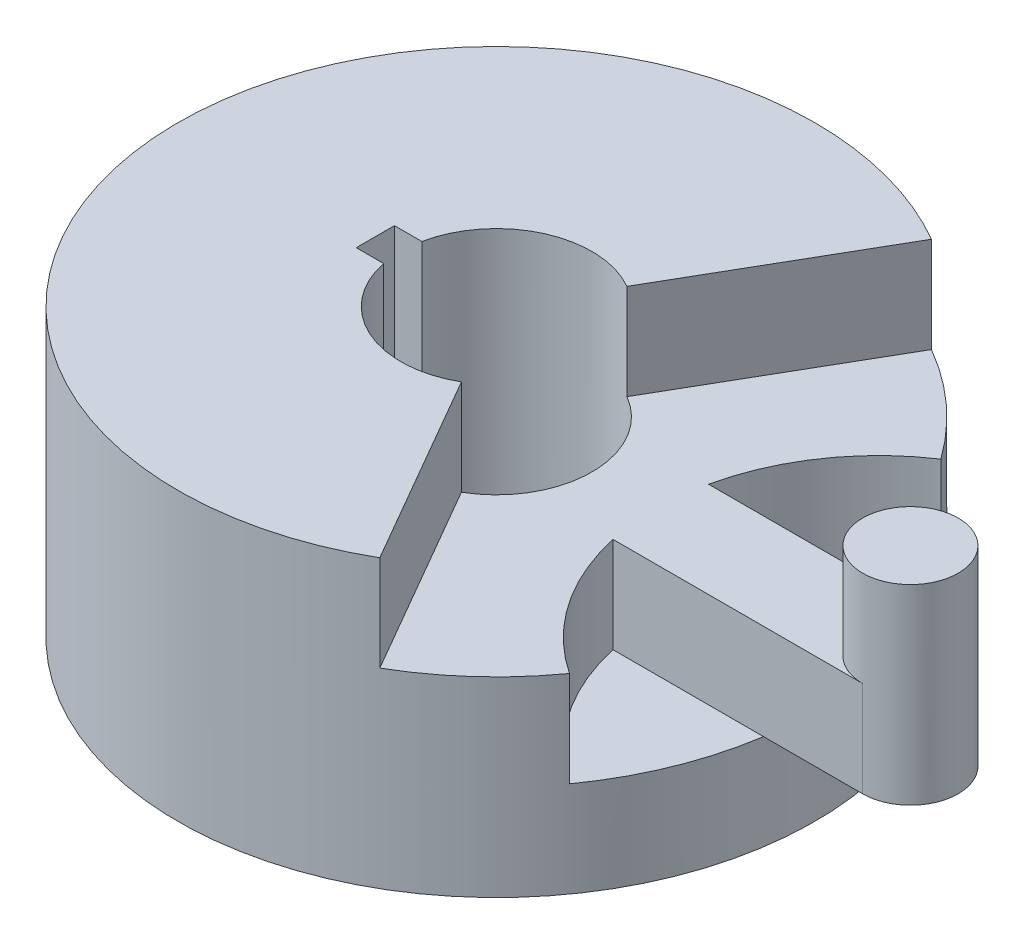
from build123d import *

# Parameters (mm, degrees)
SKETCH1_R           = 15
BOSS_EXTRUDE6_DEPTH = 15
BOSS_EXTRUDE7_DEPTH = 15
SKETCH5_R           = 7.5
BOSS_EXTRUDE8_DEPTH = 30
SKETCH6_R           = 50
BOSS_EXTRUDE9_DEPTH = 15
CUT_EXTRUDE1_DEPTH  = 15
SKETCH8_R           = 15
CUT_EXTRUDE2_DEPTH  = 16
SKETCH9_W           = 8
SKETCH9_H           = 6
CUT_EXTRUDE3_DEPTH  = 46


with BuildPart() as part:
    # Sketch1 → Boss-Extrude6 (new body, symmetric)
    with BuildSketch(Plane(origin=(0, 0, 0), x_dir=(1, 0, 0), z_dir=(0, 1, 0))):
        with BuildLine():
            ThreePointArc((40.625, 29.148059541), (-50, 0), (40.625, -29.148059541))
            ThreePointArc((40.625, -29.148059541), (25, 0), (40.625, 29.148059541))
        make_face()
        Circle(SKETCH1_R, mode=Mode.SUBTRACT)
    extrude(amount=BOSS_EXTRUDE6_DEPTH, both=True)

    # Sketch4 → Boss-Extrude7 (add)
    with BuildSketch(Plane(origin=(0, 0, 0), x_dir=(1, 0, 0), z_dir=(0, 1, 0))):
        with BuildLine():
            Line((65, 7.5), (25.813014172, 7.5))
            ThreePointArc((25.813014172, 7.5), (25, 0), (25.813014172, -7.5))
            Line((25.813014172, -7.5), (65, -7.5))
            ThreePointArc((65, -7.5), (72.5, 0), (65, 7.5))
        make_face()
    extrude(amount=-BOSS_EXTRUDE7_DEPTH)

    # Sketch5 → Boss-Extrude8 (add)
    with BuildSketch(Plane(origin=(0, 15, 0), x_dir=(1, 0, 0), z_dir=(0, 1, 0))):
        with Locations((65, 0)):
            Circle(SKETCH5_R)
    extrude(amount=-BOSS_EXTRUDE8_DEPTH)

    # Sketch6 → Boss-Extrude9 (add)
    with BuildSketch(Plane.XZ.offset(15)):
        Circle(SKETCH6_R)
    extrude(amount=BOSS_EXTRUDE9_DEPTH)

    # Sketch7 → Cut-Extrude1 (cut)
    with BuildSketch(Plane(origin=(0, 15, 0), x_dir=(1, 0, 0), z_dir=(0, 1, 0))):
        with BuildLine():
            Line((0, 0), (25, -43.301270189))
            ThreePointArc((25, -43.301270189), (33.566925673, -37.057543103), (40.625, -29.148059541))
            ThreePointArc((40.625, -29.148059541), (25, 0), (40.625, 29.148059541))
            ThreePointArc((40.625, 29.148059541), (33.566925673, 37.057543103), (25, 43.301270189))
            Line((25, 43.301270189), (0, 0))
        make_face()
    extrude(amount=-CUT_EXTRUDE1_DEPTH, mode=Mode.SUBTRACT)

    # Sketch8 → Cut-Extrude2 (cut, through all)
    with BuildSketch(Plane(origin=(0, -15, 0), x_dir=(1, 0, 0), z_dir=(0, 1, 0))):
        Circle(SKETCH8_R)
    extrude(amount=-CUT_EXTRUDE2_DEPTH, mode=Mode.SUBTRACT)

    # Sketch9 → Cut-Extrude3 (cut, through all)
    with BuildSketch(Plane(origin=(0, 15, 0), x_dir=(1, 0, 0), z_dir=(0, 1, 0))):
        with Locations((-15, 0)):
            Rectangle(SKETCH9_W, SKETCH9_H)
    extrude(amount=-CUT_EXTRUDE3_DEPTH, mode=Mode.SUBTRACT)


solid = part.part
